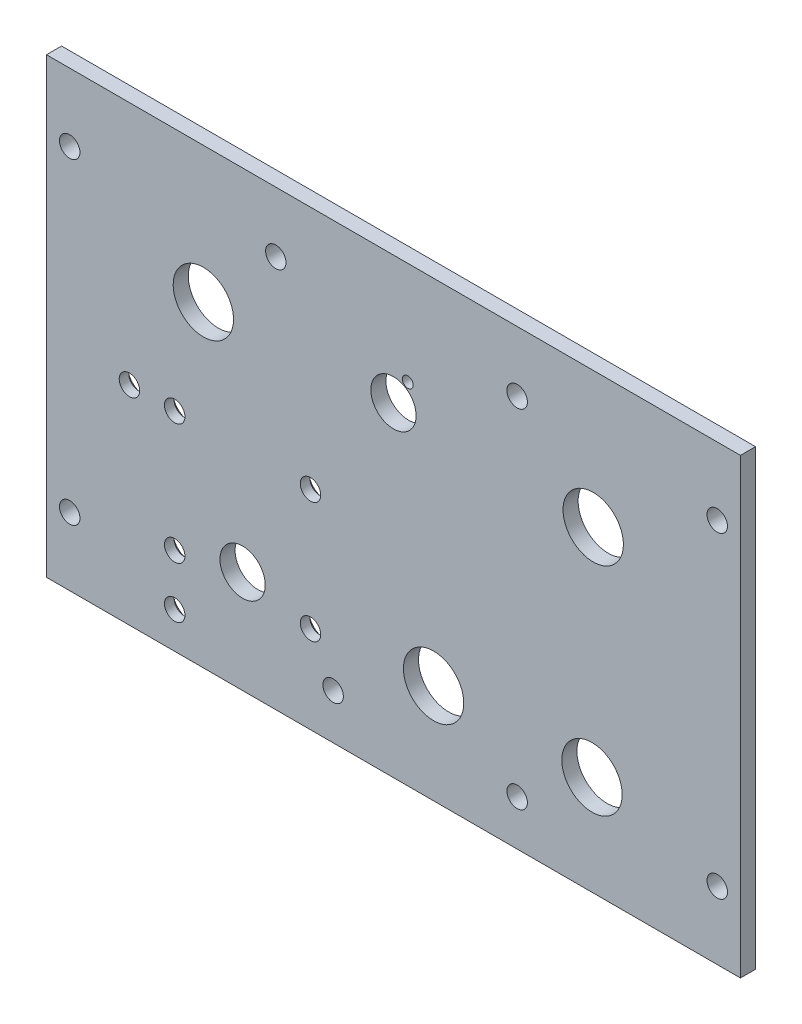
from build123d import *

# Parameters (mm, degrees)
SKETCH1_W                                         = 146.05
SKETCH1_H                                         = 95.25
BOSS_EXTRUDE1_DEPTH                               = 3.175
F_6_CLEARANCE_HOLE1_D                             = 4.3053
SKETCH5_R                                         = 6.35
SKETCH5_R_2                                       = 4.7625
CUT_EXTRUDE1_DEPTH                                = 8.4676
CSK_FOR_6_FLAT_HEAD_MACHINE_SCREW_100_D           = 4.3053
CSK_FOR_6_FLAT_HEAD_MACHINE_SCREW_100_CSINK_D     = 7.0866
CSK_FOR_6_FLAT_HEAD_MACHINE_SCREW_100_CSINK_ANGLE = 100
SKETCH8_R                                         = 1.134488875
CUT_EXTRUDE2_DEPTH                                = 4.175


with BuildPart() as part:
    # Sketch1 → Boss-Extrude1 (new body)
    with BuildSketch(Plane.XY):
        with Locations((-73.025, 47.625)):
            Rectangle(SKETCH1_W, SKETCH1_H)
    extrude(amount=-BOSS_EXTRUDE1_DEPTH)

    # #6 Clearance Hole1 (through all)
    with Locations(Plane(origin=(0, 0, -3.175), x_dir=(-1, 0, 0), z_dir=(0, 0, -1))):
        with Locations((4.8895, 80.9625), (141.1605, 80.9625), (141.1605, 14.2875), (4.8895, 14.2875), (46.99, 9.525), (85.725, 9.525), (97.79, 82.55), (46.99, 82.55)):
            Hole(F_6_CLEARANCE_HOLE1_D / 2)

    # Sketch5 → Cut-Extrude1 (cut, through all)
    with BuildSketch(Plane(origin=(0, 0, -7.4676), x_dir=(-1, 0, 0), z_dir=(0, 0, -1))):
        with Locations((30.988, 66.675)):
            Circle(SKETCH5_R)
        with Locations((113.03, 66.675)):
            Circle(SKETCH5_R)
        with Locations((64.5795, 20.955)):
            Circle(SKETCH5_R)
        with Locations((31.242, 20.955)):
            Circle(SKETCH5_R)
        with Locations((73.025, 68.326)):
            Circle(SKETCH5_R_2)
        with Locations((104.775, 21.59)):
            Circle(SKETCH5_R_2)
    extrude(amount=-CUT_EXTRUDE1_DEPTH, mode=Mode.SUBTRACT)

    # CSK for #6 Flat Head Machine Screw (100)1 (through all)
    with Locations(Plane(origin=(0, 0, -3.175), x_dir=(-1, 0, 0), z_dir=(0, 0, -1))):
        with Locations((90.4875, 43.815), (90.4875, 18.415), (119.0625, 7.636172046), (119.0625, 18.415), (119.0625, 43.815), (128.5875, 43.815)):
            CounterSinkHole(CSK_FOR_6_FLAT_HEAD_MACHINE_SCREW_100_D / 2, CSK_FOR_6_FLAT_HEAD_MACHINE_SCREW_100_CSINK_D / 2, counter_sink_angle=CSK_FOR_6_FLAT_HEAD_MACHINE_SCREW_100_CSINK_ANGLE)

    # Sketch8 → Cut-Extrude2 (cut, through all)
    with BuildSketch(Plane.XY):
        with Locations((-70.012401844, 73.606641948)):
            Circle(SKETCH8_R)
    extrude(amount=-CUT_EXTRUDE2_DEPTH, mode=Mode.SUBTRACT)


solid = part.part
